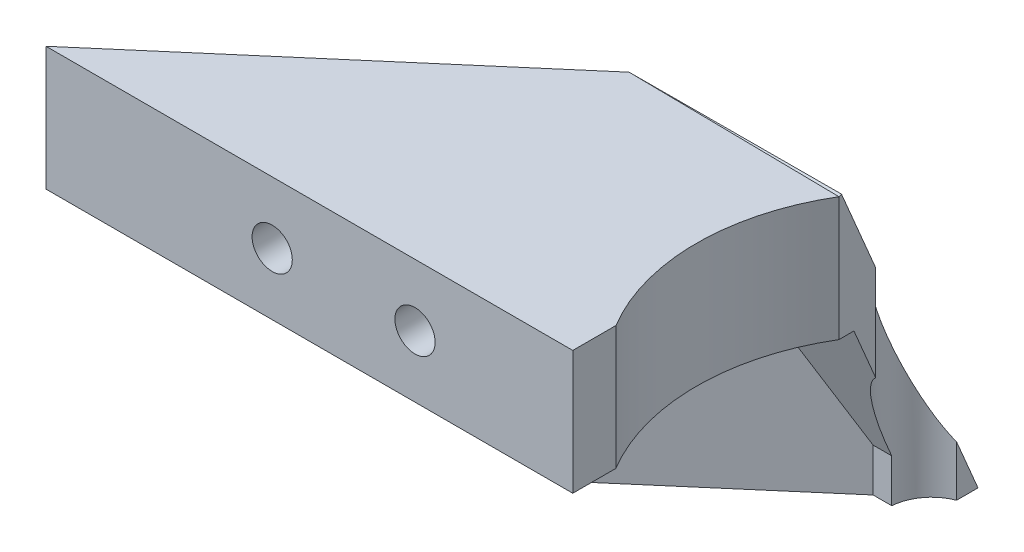
from build123d import *

# Parameters (mm, degrees)
CROQUIS1_R                              = 15.25
CROQUIS1_R_2                            = 2.125
SOPORTE_CAJA_REDUCTORA_DEPTH            = 20
CROQUIS3_R                              = 2.125
CORTAR_EXTRUIR1_DEPTH                   = 51.423828692
REDONDEO1_R                             = 5
BOSS_EXTRUDE1_DEPTH                     = 20
CUT_EXTRUDE1_REACH                      = 55.852
SKETCH2_R                               = 1.625
CUT_EXTRUDE2_DEPTH                      = 2
SKETCH4_R                               = 1.625
CUT_EXTRUDE3_DEPTH                      = 63.291652731
CUT_EXTRUDE4_START                      = -4.5
CUT_EXTRUDE4_DEPTH                      = 2
CROQUIS6_W                              = 4.75
CROQUIS6_H                              = 4.75
CORTAR_EXTRUIR17_DEPTH                  = 42.231056256
CROQUIS7_W                              = 60
CROQUIS7_H                              = 20
CORTAR_EXTRUIR18_DEPTH                  = 51.423828692
SALIENTE_EXTRUIR2_DEPTH                 = 49
SOPORTE_START                           = -15
SOPORTE_MOTOR_DEPTH                     = 15
CROQUIS12_R                             = 2.125
AGUJEROS_DE_SUJECION_A_BASE_DEPTH       = 84.087679592
TUERCA_START                            = -4
TUERCA_AGUJERO_DE_SUJECION_A_BASE_DEPTH = 10
SALIENTE_EXTRUIR4_DEPTH                 = 15
CORTAR_EXTRUIR19_DEPTH                  = 25
CROQUIS14_W                             = 50
CROQUIS14_H                             = 118
CORTAR_EXTRUIR22_DEPTH                  = 146.556045907
CROQUIS15_W                             = 10
CROQUIS15_H                             = 7
CORTAR_EXTRUIR23_DEPTH                  = 42.231056256
CORTAR_EXTRUIR24_DEPTH                  = 42.231056256
CROQUIS18_W                             = 40
CROQUIS18_H                             = 10
CORTAR_EXTRUIR25_DEPTH                  = 44.27311521
SALIENTE_EXTRUIR5_DEPTH                 = 10
CROQUIS20_R                             = 1
CORTAR_EXTRUIR26_DEPTH                  = 49.229270158
CORTAR_EXTRUIR27_REACH                  = 62.959
CORTAR_EXTRUIR27_END_RADIUS             = 15.25
CROQUIS21_R                             = 1.625
CROQUIS22_R                             = 2.125
CROQUIS22_R_2                           = 1
SALIENTE_EXTRUIR6_DEPTH                 = 10
CROQUIS23_R                             = 1.625
CORTAR_EXTRUIR28_DEPTH                  = 52.269508521
CORTAR_EXTRUIR29_START                  = -3
CORTAR_EXTRUIR29_DEPTH                  = 10
SALIENTE_EXTRUIR7_DEPTH                 = 10
CORTAR_EXTRUIR30_REACH                  = 72.235
CROQUIS27_R                             = 1.625
CORTAR_EXTRUIR31_REACH                  = 75.235
CORTAR_EXTRUIR31_START                  = -3
CORTAR_EXTRUIR32_REACH                  = 58.612
CROQUIS29_R                             = 1.625
CORTAR_EXTRUIR33_REACH                  = 61.112
CORTAR_EXTRUIR33_START                  = -2.5
CROQUIS35_W                             = 13.305418987
CROQUIS35_H                             = 6.826864192
CORTAR_EXTRUIR34_DEPTH                  = 63.931555098
CORTAR_EXTRUIR34_DEPTH_BACK             = 63.931555098
CORTAR_EXTRUIR35_START                  = -3
CORTAR_EXTRUIR35_DEPTH                  = 10
SALIENTE_EXTRUIR8_DEPTH                 = 10
SALIENTE_EXTRUIR9_DEPTH                 = 13
SALIENTE_EXTRUIR10_DEPTH                = 3
CROQUIS40_W                             = 106.583537839
CROQUIS40_H                             = 47.391515964
CORTAR_EXTRUIR36_DEPTH                  = 80.887064817
CORTAR_EXTRUIR36_DEPTH_BACK             = 80.887064817
CROQUIS41_W                             = 24.558856908
CROQUIS41_H                             = 18.206234432
CORTAR_EXTRUIR37_DEPTH                  = 80.887064817
CORTAR_EXTRUIR37_DEPTH_BACK             = 80.887064817
CROQUIS42_W                             = 39.793611955
CROQUIS42_H                             = 36.552695193
CORTAR_EXTRUIR38_DEPTH                  = 63.931555082
CORTAR_EXTRUIR38_DEPTH_BACK             = 63.931555082
SALIENTE_EXTRUIR11_DEPTH                = 3
CROQUIS44_R                             = 17.5
CORTAR_EXTRUIR39_DEPTH                  = 63.931555082
CORTAR_EXTRUIR39_DEPTH_BACK             = 63.931555082
SALIENTE_EXTRUIR12_DEPTH                = 16
CORTAR_EXTRUIR40_DEPTH                  = 66.79232953
SALIENTE_EXTRUIR14_DEPTH                = 3
CROQUIS48_R                             = 17.5
CORTAR_EXTRUIR41_DEPTH                  = 68.352658633
CORTAR_EXTRUIR41_DEPTH_BACK             = 68.352658633
CROQUIS49_R                             = 3.5
CORTAR_EXTRUIR42_DEPTH                  = 68.352658633
CROQUIS50_W                             = 95.776732481
CROQUIS50_H                             = 51.661294246
CORTAR_EXTRUIR43_DEPTH                  = 90.449033504
CORTAR_EXTRUIR43_DEPTH_BACK             = 90.449033504


with BuildPart() as part:
    # Croquis1 → Soporte caja reductora (new body)
    with BuildSketch(Plane(origin=(0, 0, 0), x_dir=(1, 0, 0), z_dir=(0, 1, 0))):
        Polygon((-30, -15.25), (-20, -15.25), (-20, -20), (20, -20), (20, -15.25), (30, -15.25), (30, -7.25), (20, -4.25), (20, 20), (-20, 20), (-20, -4.25), (-30, -7.25), align=None)
        with Locations(Location((0, 0, 0), (0, 0, 270))):
            Circle(CROQUIS1_R, mode=Mode.SUBTRACT)
        with Locations(Location((-15, 15, 0), (0, 0, 270))):
            Circle(CROQUIS1_R_2, mode=Mode.SUBTRACT)
        with Locations(Location((15, 15, 0), (0, 0, 270))):
            Circle(CROQUIS1_R_2, mode=Mode.SUBTRACT)
    extrude(amount=-SOPORTE_CAJA_REDUCTORA_DEPTH)

    # Croquis3 → Cortar-Extruir1 (cut, through all)
    with BuildSketch(Plane.XY.offset(15.25)):
        with Locations((-23.5, -10)):
            Circle(CROQUIS3_R)
        with Locations((23.5, -10)):
            Circle(CROQUIS3_R)
    extrude(amount=-CORTAR_EXTRUIR1_DEPTH, mode=Mode.SUBTRACT)

    # Redondeo1
    redondeo1_edges = [part.edges().sort_by_distance(p)[0] for p in [
        (-20, -10, -20),
        (20, -10, -20),
    ]]
    fillet(redondeo1_edges, radius=REDONDEO1_R)

    # Sketch1 → Boss-Extrude1 (add)
    with BuildSketch(Plane(origin=(0, 0, 0), x_dir=(1, 0, 0), z_dir=(0, 1, 0))):
        with BuildLine():
            Line((25.5, 15), (20, 15))
            ThreePointArc((20, 15), (18.535533906, 18.535533906), (15, 20))
            Line((15, 20), (30, 20))
            Line((30, 20), (30, 8))
            Line((30, 8), (25.5, 8))
            Line((25.5, 8), (25.5, 15))
        make_face()
    extrude(amount=-BOSS_EXTRUDE1_DEPTH)

    # Sketch2 → Cut-Extrude1 (cut, up to next)
    with BuildSketch(Plane(origin=(0, 0, -20), x_dir=(-1, 0, 0), z_dir=(0, 0, -1)), mode=Mode.PRIVATE) as cut_extrude1_sk1:
        with Locations((-22.75, -10)):
            Circle(SKETCH2_R)
    cut_extrude1_tool1 = extrude(cut_extrude1_sk1.sketch, amount=-CUT_EXTRUDE1_REACH, mode=Mode.PRIVATE) & part.part
    add(cut_extrude1_tool1.solids().sort_by_distance((22.75, -10, -20))[0], mode=Mode.SUBTRACT)

    # Sketch3 → Cut-Extrude2 (cut)
    with BuildSketch(Plane.XY.offset(-15)):
        Polygon((20, -11.58771324), (22.75, -13.175426481), (25.5, -11.58771324), (25.5, -8.41228676), (22.75, -6.824573519), (20, -8.41228676), align=None)
    extrude(amount=-CUT_EXTRUDE2_DEPTH, mode=Mode.SUBTRACT)

    # Sketch4 → Cut-Extrude3 (cut, through all)
    with BuildSketch(Plane.ZY.offset(-25.5)):
        with Locations((-12.25, -10)):
            Circle(SKETCH4_R)
    extrude(amount=-CUT_EXTRUDE3_DEPTH, mode=Mode.SUBTRACT)

    # Sketch5 → Cut-Extrude4 (cut)
    with BuildSketch(Plane(origin=(30, 0, 0), x_dir=(0, 0, -1), z_dir=(1, 0, 0)).offset(CUT_EXTRUDE4_START)):
        Polygon((15, -11.58771324), (15, -8.41228676), (12.25, -6.824573519), (9.5, -8.41228676), (9.5, -11.58771324), (12.25, -13.175426481), align=None)
    extrude(amount=CUT_EXTRUDE4_DEPTH, mode=Mode.SUBTRACT)

    # Croquis6 → Cortar-Extruir17 (cut, through all)
    with BuildSketch(Plane(origin=(0, 0, 0), x_dir=(1, 0, 0), z_dir=(0, 1, 0))):
        Polygon((0, -15.25), (-15.25, -15.25), (-15.25, -20), (15.25, -20), (15.25, -15.25), align=None)
        with Locations((-17.625, -17.625)):
            Rectangle(CROQUIS6_W, CROQUIS6_H)
        with BuildLine():
            ThreePointArc((0, -15.25), (-10.783378413, -10.783378413), (-15.25, 0))
            Line((-15.25, 0), (-15.25, -15.25))
            Line((-15.25, -15.25), (0, -15.25))
        make_face()
        with BuildLine():
            Line((15.25, -15.25), (15.25, 0))
            ThreePointArc((15.25, 0), (10.783378413, -10.783378413), (0, -15.25))
            Line((0, -15.25), (15.25, -15.25))
        make_face()
        with Locations((17.625, -17.625)):
            Rectangle(CROQUIS6_W, CROQUIS6_H)
    extrude(amount=-CORTAR_EXTRUIR17_DEPTH, mode=Mode.SUBTRACT)


with BuildPart() as body_2:
    # Simetría1: mirrored copy
    add(part.part.mirror(Plane.ZX))

    # Croquis8 → Saliente-Extruir2 (add)
    with BuildSketch(Plane(origin=(0, 20, 0), x_dir=(1, 0, 0), z_dir=(0, 1, 0))):
        with BuildLine():
            Line((-12.664515522, 20), (-11.040489496, 13.939052358))
            Line((-11.040489496, 13.939052358), (-10.315162126, 11.232093763))
            ThreePointArc((-10.315162126, 11.232093763), (0, 15.25), (10.315162126, 11.232093763))
            Line((10.315162126, 11.232093763), (10.817418481, 13.87928066))
            Line((10.817418481, 13.87928066), (11.978715476, 20))
            Line((11.978715476, 20), (-12.664515522, 20))
        make_face()
    extrude(amount=SALIENTE_EXTRUIR2_DEPTH)

    # Croquis9 → Soporte motor (add)
    with BuildSketch(Plane(origin=(0, 69, 0), x_dir=(1, 0, 0), z_dir=(0, 1, 0)).offset(SOPORTE_START)):
        with BuildLine():
            Line((-20, 15), (-20, -4.25))
            Line((-20, -4.25), (-30, -7.25))
            Line((-30, -7.25), (-30, -15.25))
            Line((-30, -15.25), (0, -15.25))
            Line((0, -15.25), (0, -14.75))
            ThreePointArc((0, -14.75), (-10.429825023, 10.429825023), (14.75, 0))
            Line((14.75, 0), (20, 0))
            Line((20, 0), (20, 13.936837101))
            Line((20, 13.936837101), (12.664515522, 20))
            Line((12.664515522, 20), (-15, 20))
            ThreePointArc((-15, 20), (-18.535533906, 18.535533906), (-20, 15))
        make_face()
    extrude(amount=-SOPORTE_MOTOR_DEPTH)

    # Croquis12 → Agujeros de sujecion a base (cut, through all)
    with BuildSketch(Plane.XY.offset(15.25)):
        with Locations((-23.5, 46.5)):
            Circle(CROQUIS12_R)
    extrude(amount=-AGUJEROS_DE_SUJECION_A_BASE_DEPTH, mode=Mode.SUBTRACT)

    # Croquis13 → Tuerca Agujero de sujecion a base (cut)
    with BuildSketch(Plane.XY.offset(15.25).offset(TUERCA_START)):
        Polygon((-20, 44.479274058), (-20, 48.520725942), (-23.5, 50.541451884), (-27, 48.520725942), (-27, 44.479274058), (-23.5, 42.458548116), align=None)
    extrude(amount=-TUERCA_AGUJERO_DE_SUJECION_A_BASE_DEPTH, mode=Mode.SUBTRACT)

    # Croquis10 → Saliente-Extruir4 (add)
    with BuildSketch(Plane(origin=(0, 69, 0), x_dir=(1, 0, 0), z_dir=(0, 1, 0))):
        with BuildLine():
            ThreePointArc((10.315162126, 11.232093763), (0, 15.25), (-10.315162126, 11.232093763))
            Line((-10.315162126, 11.232093763), (-10.16850369, 10.684757026))
            ThreePointArc((-10.16850369, 10.684757026), (0, 14.75), (10.16850369, 10.684757026))
            Line((10.16850369, 10.684757026), (10.315162126, 11.232093763))
        make_face()
    extrude(amount=-SALIENTE_EXTRUIR4_DEPTH)

    # Croquis11 → Cortar-Extruir19 (cut)
    with BuildSketch(Plane.XZ):
        with BuildLine():
            Line((15.25, 4.25), (20, 4.25))
            Line((20, 4.25), (21.972856468, 4.84185694))
            ThreePointArc((21.972856468, 4.84185694), (19.948931102, 10.40625523), (16.543503257, 15.25))
            Line((16.543503257, 15.25), (15.25, 15.25))
            Line((15.25, 15.25), (15.25, 4.25))
        make_face()
        with BuildLine():
            Line((21.972856468, 4.84185694), (30, 7.25))
            Line((30, 7.25), (30, 15.25))
            Line((30, 15.25), (16.543503257, 15.25))
            ThreePointArc((16.543503257, 15.25), (19.948931102, 10.40625523), (21.972856468, 4.84185694))
        make_face()
        with BuildLine():
            ThreePointArc((20, -15), (18.535533906, -18.535533906), (15, -20))
            Line((15, -20), (30, -20))
            Line((30, -20), (30, -8))
            Line((30, -8), (25.5, -8))
            Line((25.5, -8), (25.5, -15))
            Line((25.5, -15), (20, -15))
        make_face()
    extrude(amount=-CORTAR_EXTRUIR19_DEPTH, mode=Mode.SUBTRACT)

    # Simetría2: body 2 across face


with BuildPart() as part_1:
    add(part.part)

    # Croquis7 → Cortar-Extruir18 (cut, through all)
    with BuildSketch(Plane(origin=(0, 0, -20), x_dir=(-1, 0, 0), z_dir=(0, 0, -1))):
        with Locations((0, -10)):
            Rectangle(CROQUIS7_W, CROQUIS7_H)
    extrude(amount=-CORTAR_EXTRUIR18_DEPTH, mode=Mode.SUBTRACT)


with BuildPart() as body_2_1:
    add(body_2.part)
    add(body_2.part.mirror(Plane(origin=(-0.229209569, 69, -16.663998028), x_dir=(0, 0, 1), z_dir=(0, 1, 0))))

    # Croquis14 → Cortar-Extruir22 (cut, through all)
    with BuildSketch(Plane.XY.offset(15.25)):
        with Locations((-5, 79)):
            Rectangle(CROQUIS14_W, CROQUIS14_H)
    extrude(amount=-CORTAR_EXTRUIR22_DEPTH, mode=Mode.SUBTRACT)

    # Croquis15 → Cortar-Extruir23 (cut, through all)
    with BuildSketch(Plane.XZ):
        with Locations((-25, 7.75)):
            Rectangle(CROQUIS15_W, CROQUIS15_H)
    extrude(amount=-CORTAR_EXTRUIR23_DEPTH, mode=Mode.SUBTRACT)

    # Croquis16 → Cortar-Extruir24 (cut, through all)
    with BuildSketch(Plane.XZ):
        Polygon((-30, 15.25), (-15.25, 15.25), (-15.25, 12.75), (-20, 12.75), (-20, 11.25), (-30, 11.25), (-30, 12.75), align=None)
    extrude(amount=-CORTAR_EXTRUIR24_DEPTH, mode=Mode.SUBTRACT)

    # Croquis18 → Cortar-Extruir25 (cut, through all)
    with BuildSketch(Plane(origin=(0, 0, -20), x_dir=(-1, 0, 0), z_dir=(0, 0, -1))):
        with Locations((0, 5)):
            Rectangle(CROQUIS18_W, CROQUIS18_H)
    extrude(amount=-CORTAR_EXTRUIR25_DEPTH, mode=Mode.SUBTRACT)

    # Croquis19 → Saliente-Extruir5 (add)
    with BuildSketch(Plane(origin=(0, 20, 0), x_dir=(1, 0, 0), z_dir=(0, 1, 0))):
        Polygon((-20, -12.75), (-34, -12.75), (-34, -7.75), (-24, -7.75), (-20, -3.75), align=None)
    extrude(amount=-SALIENTE_EXTRUIR5_DEPTH)

    # Croquis20 → Cortar-Extruir26 (cut, through all)
    with BuildSketch(Plane(origin=(0, 0, 7.75), x_dir=(-1, 0, 0), z_dir=(0, 0, -1))):
        with Locations((29, 15)):
            Circle(CROQUIS20_R)
    extrude(amount=-CORTAR_EXTRUIR26_DEPTH, mode=Mode.SUBTRACT)

    # Cortar-Extruir27: up to this cylinder (the profile starts outside it)
    cortar_extruir27_end = Plane(origin=(0, 15, 0), z_dir=(0, -1, 0)) * Cylinder(CORTAR_EXTRUIR27_END_RADIUS, 157.418, mode=Mode.PRIVATE)
    # Croquis21 → Cortar-Extruir27 (cut, up to the surface)
    with BuildSketch(Plane(origin=(20, 0, 0), x_dir=(0, 0, -1), z_dir=(1, 0, 0)), mode=Mode.PRIVATE) as cortar_extruir27_sk1:
        with Locations((4.75, 15)):
            Circle(CROQUIS21_R)
    cortar_extruir27_tool1 = extrude(cortar_extruir27_sk1.sketch, amount=-CORTAR_EXTRUIR27_REACH, mode=Mode.PRIVATE) - cortar_extruir27_end
    add(cortar_extruir27_tool1.solids().sort_by_distance((20, 15, -4.75))[0], mode=Mode.SUBTRACT)

    # Croquis22 → Saliente-Extruir6 (add)
    with BuildSketch(Plane.XZ.offset(-10)):
        with Locations((-15, -15)):
            Circle(CROQUIS22_R)
        with Locations(Location((-15, -15, 0), (0, 0, 270))):
            Circle(CROQUIS22_R_2, mode=Mode.SUBTRACT)
        with Locations((15, -15)):
            Circle(CROQUIS22_R)
        with Locations(Location((15, -15, 0), (0, 0, 270))):
            Circle(CROQUIS22_R_2, mode=Mode.SUBTRACT)
    extrude(amount=-SALIENTE_EXTRUIR6_DEPTH)

    # Croquis23 → Cortar-Extruir28 (cut, through all)
    with BuildSketch(Plane(origin=(0, 0, -20), x_dir=(-1, 0, 0), z_dir=(0, 0, -1))):
        with Locations((0, 15)):
            Circle(CROQUIS23_R)
    extrude(amount=-CORTAR_EXTRUIR28_DEPTH, mode=Mode.SUBTRACT)

    # Croquis24 → Cortar-Extruir29 (cut)
    with BuildSketch(Plane(origin=(0, 0, -20), x_dir=(-1, 0, 0), z_dir=(0, 0, -1)).offset(CORTAR_EXTRUIR29_START)):
        Polygon((1.58771324, 12.25), (3.175426481, 15), (1.58771324, 17.75), (-1.58771324, 17.75), (-3.175426481, 15), (-1.58771324, 12.25), align=None)
    extrude(amount=-CORTAR_EXTRUIR29_DEPTH, mode=Mode.SUBTRACT)

    # Croquis26 → Saliente-Extruir7 (add)
    with BuildSketch(Plane.XZ.offset(-10)):
        Polygon((-34, 7.75), (-34, 12.75), (-58.825, 12.75), (-39.160527763, -4.104491148), (-20, -4.104491148), (-20, -0.104491148), (-35.732113118, -0.104491148), (-29, 7.75), align=None)
        Polygon((-34.268209086, 7.75), (-39.594516123, 1.535690951), (-46.844874897, 7.75), align=None, mode=Mode.SUBTRACT)
    extrude(amount=-SALIENTE_EXTRUIR7_DEPTH)

    # Croquis27 → Cortar-Extruir30 (cut, up to next)
    with BuildSketch(Plane.XY.offset(12.75), mode=Mode.PRIVATE) as cortar_extruir30_sk1:
        with Locations((-40.544874897, 15)):
            Circle(CROQUIS27_R)
    cortar_extruir30_tool1 = extrude(cortar_extruir30_sk1.sketch, amount=-CORTAR_EXTRUIR30_REACH, mode=Mode.PRIVATE) & body_2_1.part
    # Croquis27 → Cortar-Extruir30 (cut, up to next)
    with BuildSketch(Plane.XY.offset(12.75), mode=Mode.PRIVATE) as cortar_extruir30_sk2:
        with Locations((-29, 15)):
            Circle(CROQUIS27_R)
    cortar_extruir30_tool2 = extrude(cortar_extruir30_sk2.sketch, amount=-CORTAR_EXTRUIR30_REACH, mode=Mode.PRIVATE) & body_2_1.part
    add(cortar_extruir30_tool1.solids().sort_by_distance((-40.544875, 15, 12.75))[0], mode=Mode.SUBTRACT)
    add(cortar_extruir30_tool2.solids().sort_by_distance((-29, 15, 12.75))[0], mode=Mode.SUBTRACT)

    # Croquis28 → Cortar-Extruir31 (cut, up to next)
    with BuildSketch(Plane.XY.offset(12.75).offset(CORTAR_EXTRUIR31_START), mode=Mode.PRIVATE) as cortar_extruir31_sk1:
        Polygon((-38.957161657, 12.25), (-37.369448416, 15), (-38.957161657, 17.75), (-42.132588137, 17.75), (-43.720301378, 15), (-42.132588137, 12.25), align=None)
    cortar_extruir31_tool1 = extrude(cortar_extruir31_sk1.sketch, amount=-CORTAR_EXTRUIR31_REACH, mode=Mode.PRIVATE) & body_2_1.part
    # Croquis28 → Cortar-Extruir31 (cut, up to next)
    with BuildSketch(Plane.XY.offset(12.75).offset(CORTAR_EXTRUIR31_START), mode=Mode.PRIVATE) as cortar_extruir31_sk2:
        Polygon((-27.41228676, 12.25), (-25.824573519, 15), (-27.41228676, 17.75), (-30.58771324, 17.75), (-32.175426481, 15), (-30.58771324, 12.25), align=None)
    cortar_extruir31_tool2 = extrude(cortar_extruir31_sk2.sketch, amount=-CORTAR_EXTRUIR31_REACH, mode=Mode.PRIVATE) & body_2_1.part
    add(cortar_extruir31_tool1.solids().sort_by_distance((-40.544875, 15, 9.75))[0], mode=Mode.SUBTRACT)
    add(cortar_extruir31_tool2.solids().sort_by_distance((-29, 15, 9.75))[0], mode=Mode.SUBTRACT)

    # Croquis29 → Cortar-Extruir32 (cut, up to next)
    with BuildSketch(Plane(origin=(-18.612848159, 0, -21.715982563), x_dir=(-0.7592713073348843, 0, 0.6507742172658468), z_dir=(-0.6507742172658468, 0, -0.7592713073348843)), mode=Mode.PRIVATE) as cortar_extruir32_sk1:
        with Locations((33.812368097, 15)):
            Circle(CROQUIS29_R)
    cortar_extruir32_tool1 = extrude(cortar_extruir32_sk1.sketch, amount=-CORTAR_EXTRUIR32_REACH, mode=Mode.PRIVATE) & body_2_1.part
    add(cortar_extruir32_tool1.solids().sort_by_distance((-44.285609, 15, 0.288235))[0], mode=Mode.SUBTRACT)

    # Croquis31 → Cortar-Extruir33 (cut, up to next)
    with BuildSketch(Plane(origin=(-18.612848159, 0, -21.715982563), x_dir=(-0.7592713073348843, 0, 0.6507742172658468), z_dir=(-0.6507742172658468, 0, -0.7592713073348843)).offset(CORTAR_EXTRUIR33_START), mode=Mode.PRIVATE) as cortar_extruir33_sk1:
        Polygon((36.562368097, 16.58771324), (33.812368097, 18.175426481), (31.062368097, 16.58771324), (31.062368097, 13.41228676), (33.812368097, 11.824573519), (36.562368097, 13.41228676), align=None)
    cortar_extruir33_tool1 = extrude(cortar_extruir33_sk1.sketch, amount=-CORTAR_EXTRUIR33_REACH, mode=Mode.PRIVATE) & body_2_1.part
    add(cortar_extruir33_tool1.solids().sort_by_distance((-42.658674, 15, 2.186413))[0], mode=Mode.SUBTRACT)

    # Croquis35 → Cortar-Extruir34 (cut, two sides)
    with BuildSketch(Plane(origin=(0, 20, 0), x_dir=(1, 0, 0), z_dir=(0, 1, 0))) as cortar_extruir34_sk:
        with Locations((17.04227466, -3.413432096)):
            Rectangle(CROQUIS35_W, CROQUIS35_H)
    extrude(amount=CORTAR_EXTRUIR34_DEPTH, mode=Mode.SUBTRACT)
    extrude(cortar_extruir34_sk.sketch, amount=-CORTAR_EXTRUIR34_DEPTH_BACK, mode=Mode.SUBTRACT)

    # Croquis36 → Cortar-Extruir35 (cut)
    with BuildSketch(Plane(origin=(20, 0, 0), x_dir=(0, 0, -1), z_dir=(1, 0, 0)).offset(CORTAR_EXTRUIR35_START)):
        Polygon((7.5, 16.58771324), (4.75, 18.175426481), (2, 16.58771324), (2, 13.41228676), (4.75, 11.824573519), (7.5, 13.41228676), align=None)
    extrude(amount=-CORTAR_EXTRUIR35_DEPTH, mode=Mode.SUBTRACT)

    # Croquis37 → Saliente-Extruir8 (add)
    with BuildSketch(Plane.XZ.offset(-10)):
        Polygon((-39.160527763, -4.104491148), (-20.614919368, -20), (-15, -20), (-19.558128305, -15.637570403), (-33.014002756, -4.104491148), align=None)
    extrude(amount=-SALIENTE_EXTRUIR8_DEPTH)

    # Croquis38 → Saliente-Extruir9 (add)
    with BuildSketch(Plane.XZ.offset(-10)):
        Polygon((-58.825, 12.75), (-38.825, 12.75), (-38.825, 9.75), (-55.324839942, 9.75), align=None)
    extrude(amount=SALIENTE_EXTRUIR9_DEPTH)

    # Croquis39 → Saliente-Extruir10 (add)
    with BuildSketch(Plane.XZ.offset(-10)):
        Polygon((-38.825, 9.75), (-38.825, 7.75), (-38.825, 5.75), (-50.657959865, 5.75), (-52.991399903, 7.75), (-55.324839942, 9.75), align=None)
    extrude(amount=SALIENTE_EXTRUIR10_DEPTH)

    # Simetría3: body 2 across face


with BuildPart() as body_2_2:
    add(body_2_1.part)
    add(body_2_1.part.mirror(Plane(origin=(-18.003999227, 20, -4.220503046), x_dir=(0, 0, 1), z_dir=(0, 1, 0))))

    # Croquis40 → Cortar-Extruir36 (cut, two sides)
    with BuildSketch(Plane(origin=(0, 0, -20), x_dir=(-1, 0, 0), z_dir=(0, 0, -1))) as cortar_extruir36_sk:
        with Locations((22.395502026, -3.695757982)):
            Rectangle(CROQUIS40_W, CROQUIS40_H)
    extrude(amount=CORTAR_EXTRUIR36_DEPTH, mode=Mode.SUBTRACT)
    extrude(cortar_extruir36_sk.sketch, amount=-CORTAR_EXTRUIR36_DEPTH_BACK, mode=Mode.SUBTRACT)

    # Croquis41 → Cortar-Extruir37 (cut, two sides)
    with BuildSketch(Plane(origin=(0, 0, -20), x_dir=(-1, 0, 0), z_dir=(0, 0, -1))) as cortar_extruir37_sk:
        with Locations((51.104428454, 39.103117216)):
            Rectangle(CROQUIS41_W, CROQUIS41_H)
    extrude(amount=CORTAR_EXTRUIR37_DEPTH, mode=Mode.SUBTRACT)
    extrude(cortar_extruir37_sk.sketch, amount=-CORTAR_EXTRUIR37_DEPTH_BACK, mode=Mode.SUBTRACT)

    # Croquis42 → Cortar-Extruir38 (cut, two sides)
    with BuildSketch(Plane.XZ.offset(-20)) as cortar_extruir38_sk:
        with Locations((3.646805978, -5.526347597)):
            Rectangle(CROQUIS42_W, CROQUIS42_H)
    extrude(amount=CORTAR_EXTRUIR38_DEPTH, mode=Mode.SUBTRACT)
    extrude(cortar_extruir38_sk.sketch, amount=-CORTAR_EXTRUIR38_DEPTH_BACK, mode=Mode.SUBTRACT)

    # Croquis43 → Saliente-Extruir11 (add)
    with BuildSketch(Plane.XZ.offset(-20)):
        Polygon((-46.844874897, 7.75), (-19.56186566, 7.75), (-19.56186566, -16.371419699), align=None)
    extrude(amount=-SALIENTE_EXTRUIR11_DEPTH)

    # Croquis44 → Cortar-Extruir39 (cut, two sides)
    with BuildSketch(Plane(origin=(0, 30, 0), x_dir=(1, 0, 0), z_dir=(0, 1, 0))) as cortar_extruir39_sk:
        with Locations((-1.25, -0.25)):
            Circle(CROQUIS44_R)
    extrude(amount=CORTAR_EXTRUIR39_DEPTH, mode=Mode.SUBTRACT)
    extrude(cortar_extruir39_sk.sketch, amount=-CORTAR_EXTRUIR39_DEPTH_BACK, mode=Mode.SUBTRACT)

    # Croquis45 → Saliente-Extruir12 (add)
    with BuildSketch(Plane(origin=(0, 30, 0), x_dir=(1, 0, 0), z_dir=(0, 1, 0))):
        Polygon((-33.014002756, 4.104491148), (-39.160527763, 4.104491148), (-20.614919368, 20), (-16.25, 20), (-16.25, 15.264857309), (-19.992980133, 15.264857309), align=None)
    extrude(amount=SALIENTE_EXTRUIR12_DEPTH)

    # Croquis46 → Cortar-Extruir40 (cut, through all)
    with BuildSketch(Plane(origin=(-16.25, 0, 0), x_dir=(0, 0, -1), z_dir=(1, 0, 0))):
        Polygon((9, 20), (20, 46), (20, 20), align=None)
    extrude(amount=-CORTAR_EXTRUIR40_DEPTH, mode=Mode.SUBTRACT)

    # Croquis47 → Saliente-Extruir14 (add)
    with BuildSketch(Plane(origin=(0, -0.193224592, -0.456712673), x_dir=(-1, 0, 0), z_dir=(0, -0.38963999083669787, -0.9209672510685588))):
        Polygon((16.25, 21.834102438), (33.44883958, 21.926104939), (22.720097697, 45.526464663), (16.25, 45.526464663), align=None)
    extrude(amount=-SALIENTE_EXTRUIR14_DEPTH)

    # Croquis48 → Cortar-Extruir41 (cut, two sides)
    with BuildSketch(Plane.XZ.offset(-20)) as cortar_extruir41_sk:
        with Locations((-1.25, 0.25)):
            Circle(CROQUIS48_R)
    extrude(amount=CORTAR_EXTRUIR41_DEPTH, mode=Mode.SUBTRACT)
    extrude(cortar_extruir41_sk.sketch, amount=-CORTAR_EXTRUIR41_DEPTH_BACK, mode=Mode.SUBTRACT)

    # Croquis49 → Cortar-Extruir42 (cut, through all)
    with BuildSketch(Plane.XZ.offset(-20)):
        with Locations((-15, -15)):
            Circle(CROQUIS49_R)
    extrude(amount=-CORTAR_EXTRUIR42_DEPTH, mode=Mode.SUBTRACT)

    # Simetría4: body 2 across plane


with BuildPart() as body_2_3:
    add(body_2_2.part)
    add(body_2_2.part.mirror(Plane(origin=(0, 46, 0), x_dir=(0, 0, 1), z_dir=(0, -1, 0))))

    # Croquis50 → Cortar-Extruir43 (cut, two sides)
    with BuildSketch(Plane(origin=(-18.612848159, 0, -21.715982563), x_dir=(-0.7592713073348843, 0, 0.6507742172658468), z_dir=(-0.6507742172658468, 0, -0.7592713073348843))) as cortar_extruir43_sk:
        with Locations((14.344286106, 20.169352877)):
            Rectangle(CROQUIS50_W, CROQUIS50_H)
    extrude(amount=CORTAR_EXTRUIR43_DEPTH, mode=Mode.SUBTRACT)
    extrude(cortar_extruir43_sk.sketch, amount=-CORTAR_EXTRUIR43_DEPTH_BACK, mode=Mode.SUBTRACT)


solid = body_2_3.part
